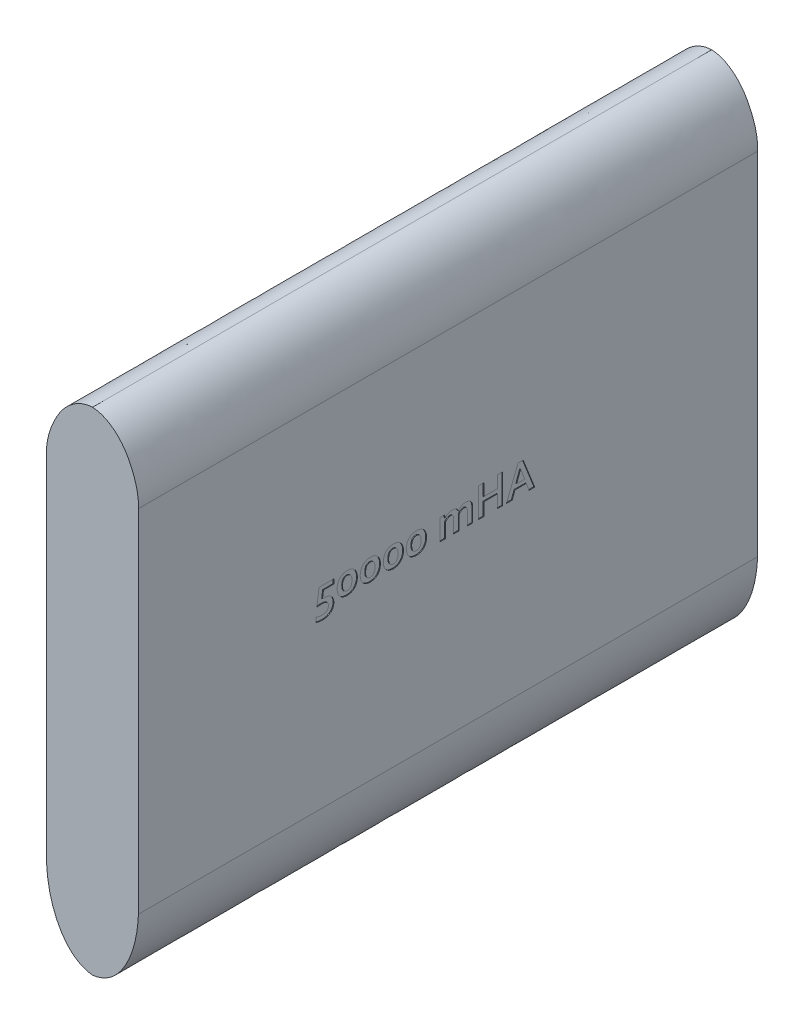
from build123d import *

# Parameters (mm, degrees)
BOSS_EXTRU_1_DEPTH      = 200
ENL_V_MAT_EXTRU_1_DEPTH = 0.25


with BuildPart() as part:
    # Esquisse1 → Boss.-Extru.1 (new body)
    with BuildSketch(Plane.XY):
        with BuildLine():
            Line((174.006058194, 716.318776113), (174.006058194, 829.741721472))
            add(Edge.make_bspline(
                [(174.006058194, 829.741721472), (173.82511917, 833.547287243), (175.407603849, 839.077084094), (180.025968772, 847.096630759), (185.137818189, 850.602101048), (188.860692851, 850.687245442)],
                knots=[0, 0, 0, 0, 0.407149215, 0.601731979, 1, 1, 1, 1], degree=3))
            add(Edge.make_bspline(
                [(203.715327508, 829.741721472), (203.896266532, 833.547287243), (202.313781853, 839.077084094), (197.69541693, 847.096630759), (192.583567513, 850.602101048), (188.860692851, 850.687245442)],
                knots=[0, 0, 0, 0, 0.407149215, 0.601731979, 1, 1, 1, 1], degree=3))
            Line((203.715327508, 829.741721472), (203.715327508, 716.318776113))
            add(Edge.make_bspline(
                [(203.715327508, 716.318776113), (203.491349962, 711.367000978), (201.646435697, 701.175584334), (194.585398748, 692.499736476), (188.860692851, 691.841289865)],
                knots=[0, 0, 0, 0, 0.482435896, 1, 1, 1, 1], degree=3))
            add(Edge.make_bspline(
                [(174.006058194, 716.318776113), (174.23003574, 711.367000978), (176.074950005, 701.175584334), (183.135986954, 692.499736476), (188.860692851, 691.841289865)],
                knots=[0, 0, 0, 0, 0.482435896, 1, 1, 1, 1], degree=3))
        make_face()
    extrude(amount=BOSS_EXTRU_1_DEPTH)

    # Esquisse3 → Enlèv. mat.-Extru.1 (cut)
    with BuildSketch(Plane(origin=(203.715327508, 0, 0), x_dir=(0, 0, -1), z_dir=(1, 0, 0))):
        with BuildLine():
            add(Edge.make_bspline(
                [(-140.546667276, 774.83369835), (-140.485009973, 774.835240725), (-140.370017677, 774.838117291), (-140.254996381, 774.839358124), (-140.201647938, 774.839933639)],
                knots=[0, 0, 0, 0, 0.000185027, 0.00034508, 0.00034508, 0.00034508, 0.00034508], degree=3))
            add(Edge.make_bspline(
                [(-140.201647938, 774.839933639), (-140.068519111, 774.837888483), (-139.809949865, 774.833916283), (-139.434787858, 774.793284398), (-139.084338789, 774.729802163), (-138.758370391, 774.641085619), (-138.458484512, 774.525851327), (-138.182172614, 774.391894468), (-137.933568705, 774.233068697), (-137.711166346, 774.053106908), (-137.515136552, 773.85242679), (-137.343305442, 773.633502134), (-137.198672667, 773.393874723), (-137.08143951, 773.135959952), (-136.986524121, 772.862083331), (-136.921275975, 772.572784649), (-136.880260316, 772.268713409), (-136.876172688, 772.06120912), (-136.874081915, 771.955073152)],
                knots=[0, 0, 0, 0, 0.000399253, 0.000775449, 0.00113052, 0.001466847, 0.001787229, 0.002093041, 0.002386512, 0.002670215, 0.002949468, 0.003226368, 0.00350333, 0.00378698, 0.004074871, 0.00437133, 0.004675278, 0.004993523, 0.004993523, 0.004993523, 0.004993523], degree=3))
            add(Edge.make_bspline(
                [(-136.874081915, 771.955073152), (-136.876682163, 771.847529419), (-136.881823113, 771.634904785), (-136.928618865, 771.321982443), (-137.006694486, 771.020222629), (-137.111666766, 770.729963965), (-137.246610554, 770.453562607), (-137.414630104, 770.197593248), (-137.608849049, 769.958522184), (-137.832376256, 769.740204818), (-138.082671873, 769.541611763), (-138.361614594, 769.367253451), (-138.665568947, 769.212339301), (-138.997477675, 769.084889337), (-139.354052186, 768.97880796), (-139.737455385, 768.909438772), (-140.144294484, 768.860953434), (-140.423885061, 768.856396106), (-140.567451573, 768.854055971)],
                knots=[0, 0, 0, 0, 0.000322485, 0.000637585, 0.000946601, 0.001256287, 0.001562098, 0.001867061, 0.002172845, 0.002484429, 0.002802538, 0.003129486, 0.003469689, 0.003824395, 0.004194688, 0.004583976, 0.004991841, 0.005422322, 0.005422322, 0.005422322, 0.005422322], degree=3))
            add(Edge.make_bspline(
                [(-140.567451573, 768.854055971), (-140.663127679, 768.854747635), (-140.851997146, 768.856113015), (-141.131157054, 768.882203987), (-141.403773032, 768.912336319), (-141.748701829, 768.980358185), (-142.156168903, 769.08310677), (-142.465253448, 769.199104577), (-142.614704873, 769.255192912)],
                knots=[0, 0, 0, 0, 0.000286891, 0.000566337, 0.000840635, 0.001109268, 0.001620443, 0.002099015, 0.002099015, 0.002099015, 0.002099015], degree=3))
            Line((-142.614704873, 769.255192912), (-142.614704873, 770.716329023))
            add(Edge.make_bspline(
                [(-142.614704873, 770.716329023), (-142.527712474, 770.682912728), (-142.357052527, 770.617357309), (-142.100582337, 770.535335396), (-141.852378036, 770.463091619), (-141.532803544, 770.392923016), (-141.145520089, 770.33091666), (-140.836518896, 770.321741955), (-140.685922069, 770.317270512)],
                knots=[0, 0, 0, 0, 0.000279508, 0.000548334, 0.000807563, 0.001054643, 0.001529654, 0.001981252, 0.001981252, 0.001981252, 0.001981252], degree=3))
            add(Edge.make_bspline(
                [(-140.685922069, 770.317270512), (-140.595804046, 770.318895283), (-140.422190904, 770.322025418), (-140.172876184, 770.344929056), (-139.943951759, 770.38146103), (-139.735760996, 770.434915752), (-139.547463568, 770.504854049), (-139.376565358, 770.582973282), (-139.222669303, 770.672666834), (-139.087392828, 770.775255926), (-138.966823786, 770.887207037), (-138.867717919, 771.013314555), (-138.782881252, 771.147282878), (-138.716741718, 771.29240751), (-138.664722574, 771.444877475), (-138.630390509, 771.605447654), (-138.605722736, 771.770712341), (-138.604135453, 771.883619196), (-138.603335463, 771.940524144)],
                knots=[0, 0, 0, 0, 0.000270324, 0.000520781, 0.000750398, 0.000965151, 0.001164388, 0.00135223, 0.001528321, 0.001697506, 0.001860699, 0.0020204, 0.002177263, 0.002335347, 0.002497691, 0.002659555, 0.002827394, 0.002997939, 0.002997939, 0.002997939, 0.002997939], degree=3))
            add(Edge.make_bspline(
                [(-138.603335463, 771.940524144), (-138.605059399, 772.001554177), (-138.608421844, 772.120590055), (-138.630806238, 772.293525283), (-138.670830289, 772.455862709), (-138.726730594, 772.608162167), (-138.79964626, 772.750074953), (-138.89009429, 772.882378912), (-139.003233382, 772.999614535), (-139.133897504, 773.106596868), (-139.281592455, 773.203037668), (-139.450800106, 773.283331789), (-139.636727503, 773.354254621), (-139.843237511, 773.409288128), (-140.067980277, 773.455237961), (-140.313738658, 773.488251082), (-140.580336447, 773.506341521), (-140.764874896, 773.508579033), (-140.860510168, 773.509738602)],
                knots=[0, 0, 0, 0, 0.000183091, 0.000357109, 0.000521948, 0.000683719, 0.000842674, 0.000999496, 0.001162689, 0.001329547, 0.00150538, 0.001690361, 0.001890322, 0.002101598, 0.002330678, 0.002578177, 0.002844873, 0.003131764, 0.003131764, 0.003131764, 0.003131764], degree=3))
            add(Edge.make_bspline(
                [(-140.860510168, 773.509738602), (-140.974159366, 773.50781456), (-141.209975207, 773.503822278), (-141.575510221, 773.480635937), (-141.967229148, 773.43845212), (-142.235878492, 773.397849158), (-142.375685452, 773.376719098)],
                knots=[0, 0, 0, 0, 0.000340964, 0.000707481, 0.001098364, 0.001522512, 0.001522512, 0.001522512, 0.001522512], degree=3))
            Line((-142.375685452, 773.376719098), (-141.65447033, 778.564479744))
            Line((-141.65447033, 778.564479744), (-136.880317204, 778.564479744))
            Line((-136.880317204, 778.564479744), (-136.880317204, 777.101265203))
            Line((-136.880317204, 777.101265203), (-140.236981244, 777.101265203))
            Line((-140.236981244, 777.101265203), (-140.546667276, 774.83369835))
        make_face()
        with BuildLine():
            add(Edge.make_bspline(
                [(-129.291970202, 775.23899215), (-129.294057874, 775.117627647), (-129.298161303, 774.87907933), (-129.339706601, 774.528315653), (-129.402600755, 774.190779425), (-129.494571438, 773.868253875), (-129.610365992, 773.562533487), (-129.750882617, 773.275654926), (-129.922073287, 773.013158699), (-130.111850547, 772.768317), (-130.329829554, 772.548865344), (-130.57337718, 772.354005454), (-130.842487622, 772.183449377), (-131.136129188, 772.037989561), (-131.453684852, 771.919446324), (-131.797576961, 771.840854899), (-132.164177063, 771.789166311), (-132.417048325, 771.783428831), (-132.546791184, 771.780485053)],
                knots=[0, 0, 0, 0, 0.000363939, 0.000715341, 0.001058156, 0.001393041, 0.00171999, 0.002037881, 0.002349208, 0.002658559, 0.002965724, 0.00327474, 0.003592441, 0.003919627, 0.004256307, 0.004606675, 0.004975864, 0.005364886, 0.005364886, 0.005364886, 0.005364886], degree=3))
            add(Edge.make_bspline(
                [(-132.546791184, 771.780485053), (-132.674451607, 771.783468212), (-132.923862323, 771.789296421), (-133.285699177, 771.840701509), (-133.626530131, 771.92022043), (-133.942423387, 772.037499275), (-134.234610031, 772.183376137), (-134.502085455, 772.355135129), (-134.747280825, 772.549276786), (-134.969049244, 772.76822434), (-135.163393066, 773.012394669), (-135.336069767, 773.27613215), (-135.481126548, 773.562291327), (-135.601496238, 773.867753538), (-135.695040467, 774.190731523), (-135.76002194, 774.528229534), (-135.804293075, 774.87894579), (-135.808026893, 775.117609567), (-135.809925885, 775.23899215)],
                knots=[0, 0, 0, 0, 0.000382792, 0.000747863, 0.001094188, 0.001430868, 0.001756194, 0.002072143, 0.002382783, 0.002692887, 0.003004825, 0.003317281, 0.003637042, 0.003965493, 0.004300952, 0.004644164, 0.004995805, 0.005359744, 0.005359744, 0.005359744, 0.005359744], degree=3))
            add(Edge.make_bspline(
                [(-135.809925885, 775.23899215), (-135.808027098, 775.360374868), (-135.804293683, 775.59903891), (-135.760019629, 775.949753247), (-135.695048831, 776.287258279), (-135.60146604, 776.610210901), (-135.481235494, 776.915764628), (-135.335414386, 777.20211382), (-135.164159308, 777.467489641), (-134.968383905, 777.711927912), (-134.747292703, 777.932657317), (-134.50328993, 778.129417387), (-134.234338252, 778.29849302), (-133.94244216, 778.442993963), (-133.625753399, 778.556442254), (-133.28628588, 778.640922241), (-132.92360555, 778.687709729), (-132.674396069, 778.694184113), (-132.546791184, 778.697499248)],
                knots=[0, 0, 0, 0, 0.000363939, 0.000715581, 0.001058792, 0.001394251, 0.001722702, 0.002042463, 0.002356664, 0.002668601, 0.002980172, 0.003292109, 0.003606942, 0.003931343, 0.00426731, 0.004614128, 0.004978921, 0.005361713, 0.005361713, 0.005361713, 0.005361713], degree=3))
            add(Edge.make_bspline(
                [(-132.546791184, 778.697499248), (-132.417103831, 778.694220555), (-132.164432452, 778.687832641), (-131.796994758, 778.64077474), (-131.45445858, 778.557217752), (-131.13610581, 778.442506788), (-130.842760514, 778.298416859), (-130.572172743, 778.130547238), (-130.329810986, 777.933068853), (-130.112514335, 777.71184886), (-129.921313392, 777.466714367), (-129.751530902, 777.202600777), (-129.610257278, 776.915521358), (-129.494601684, 776.609710799), (-129.402592363, 776.287210321), (-129.339708921, 775.949667142), (-129.298160693, 775.598905367), (-129.294057668, 775.360356788), (-129.291970202, 775.23899215)],
                knots=[0, 0, 0, 0, 0.000389022, 0.000757936, 0.001108791, 0.001444758, 0.001771025, 0.002087615, 0.002397935, 0.002706581, 0.003015932, 0.00332901, 0.003646901, 0.003973849, 0.004308734, 0.004651549, 0.005002951, 0.00536689, 0.00536689, 0.00536689, 0.00536689], degree=3))
        make_face()
        with BuildLine():
            add(Edge.make_bspline(
                [(-131.02122375, 775.23899215), (-131.022382637, 775.322160343), (-131.024635923, 775.48386872), (-131.043081685, 775.718553707), (-131.075194854, 775.938279319), (-131.114569144, 776.143962274), (-131.1713829, 776.334273995), (-131.240327868, 776.509076182), (-131.318479454, 776.671215171), (-131.4123635, 776.81622254), (-131.51656081, 776.946050797), (-131.630754569, 777.059645231), (-131.757829273, 777.153377694), (-131.893184249, 777.234158364), (-132.041902625, 777.294383265), (-132.201557251, 777.334526878), (-132.370463967, 777.363603349), (-132.487077614, 777.366050906), (-132.546791184, 777.36730421)],
                knots=[0, 0, 0, 0, 0.000249489, 0.000485096, 0.000705547, 0.000915468, 0.001112755, 0.001300332, 0.001478799, 0.001651759, 0.001817304, 0.001977505, 0.002133387, 0.002289878, 0.002449282, 0.00261262, 0.002783128, 0.002962066, 0.002962066, 0.002962066, 0.002962066], degree=3))
            add(Edge.make_bspline(
                [(-132.546791184, 777.36730421), (-132.607191427, 777.366031148), (-132.725170792, 777.363544485), (-132.895547639, 777.334838974), (-133.056401014, 777.294011847), (-133.206498929, 777.234112132), (-133.34382354, 777.154074516), (-133.471176198, 777.058927827), (-133.587298958, 776.946728223), (-133.691986112, 776.816825535), (-133.782473559, 776.669940713), (-133.864839438, 776.510243438), (-133.92966256, 776.33364661), (-133.987597296, 776.144075843), (-134.026622953, 775.938246436), (-134.058837302, 775.718563327), (-134.077253876, 775.483866078), (-134.079511314, 775.322159446), (-134.080672336, 775.23899215)],
                knots=[0, 0, 0, 0, 0.000181014, 0.000353574, 0.000516913, 0.000678242, 0.000836531, 0.000992413, 0.001154104, 0.001319649, 0.001491494, 0.00167089, 0.001857718, 0.002055004, 0.002264926, 0.002485377, 0.002720983, 0.002970472, 0.002970472, 0.002970472, 0.002970472], degree=3))
            add(Edge.make_bspline(
                [(-134.080672336, 775.23899215), (-134.079511314, 775.155824855), (-134.077253876, 774.994118223), (-134.058837302, 774.759420973), (-134.026622953, 774.539737865), (-133.987597296, 774.333908458), (-133.92966256, 774.144337691), (-133.864839438, 773.967740863), (-133.782473559, 773.808043588), (-133.691986112, 773.661158766), (-133.587298958, 773.531256078), (-133.471176198, 773.419056474), (-133.34382354, 773.323909785), (-133.206498929, 773.243872169), (-133.056401014, 773.183972454), (-132.895547639, 773.143145327), (-132.725170792, 773.114439816), (-132.607191427, 773.111953153), (-132.546791184, 773.110680091)],
                knots=[0, 0, 0, 0, 0.000249489, 0.000485096, 0.000705547, 0.000915468, 0.001112755, 0.001299582, 0.001478979, 0.001650823, 0.001816369, 0.001978059, 0.002133942, 0.00229223, 0.00245356, 0.002616898, 0.002789458, 0.002970472, 0.002970472, 0.002970472, 0.002970472], degree=3))
            add(Edge.make_bspline(
                [(-132.546791184, 773.110680091), (-132.487077614, 773.111933395), (-132.370463967, 773.114380952), (-132.201557251, 773.143457423), (-132.041902625, 773.183601036), (-131.893184249, 773.243825937), (-131.757829273, 773.324606606), (-131.630754569, 773.41833907), (-131.51656081, 773.531933504), (-131.4123635, 773.661761761), (-131.318479454, 773.806769129), (-131.240327868, 773.968908119), (-131.1713829, 774.143710306), (-131.114569144, 774.334022027), (-131.075194854, 774.539704982), (-131.043081685, 774.759430593), (-131.024635923, 774.994115581), (-131.022382637, 775.155823957), (-131.02122375, 775.23899215)],
                knots=[0, 0, 0, 0, 0.000178938, 0.000349445, 0.000512784, 0.000672188, 0.000828678, 0.000984561, 0.001144762, 0.001310307, 0.001483267, 0.001661734, 0.001849311, 0.002046598, 0.002256519, 0.00247697, 0.002712576, 0.002962066, 0.002962066, 0.002962066, 0.002962066], degree=3))
        make_face(mode=Mode.SUBTRACT)
        with BuildLine():
            add(Edge.make_bspline(
                [(-121.842877992, 775.23899215), (-121.844965664, 775.117627647), (-121.849069094, 774.87907933), (-121.890614391, 774.528315653), (-121.953508545, 774.190779425), (-122.045479228, 773.868253875), (-122.161273783, 773.562533487), (-122.301790407, 773.275654926), (-122.472981077, 773.013158699), (-122.662758338, 772.768317), (-122.880737345, 772.548865344), (-123.124284971, 772.354005454), (-123.393395412, 772.183449377), (-123.687036979, 772.037989561), (-124.004592642, 771.919446324), (-124.348484751, 771.840854899), (-124.715084854, 771.789166311), (-124.967956115, 771.783428831), (-125.097698974, 771.780485053)],
                knots=[0, 0, 0, 0, 0.000363939, 0.000715341, 0.001058156, 0.001393041, 0.00171999, 0.002037881, 0.002349208, 0.002658559, 0.002965724, 0.00327474, 0.003592441, 0.003919627, 0.004256307, 0.004606675, 0.004975864, 0.005364886, 0.005364886, 0.005364886, 0.005364886], degree=3))
            add(Edge.make_bspline(
                [(-125.097698974, 771.780485053), (-125.225359397, 771.783468212), (-125.474770114, 771.789296421), (-125.836606968, 771.840701509), (-126.177437921, 771.92022043), (-126.493331177, 772.037499275), (-126.785517821, 772.183376137), (-127.052993245, 772.355135129), (-127.298188615, 772.549276786), (-127.519957035, 772.76822434), (-127.714300857, 773.012394669), (-127.886977557, 773.27613215), (-128.032034338, 773.562291327), (-128.152404028, 773.867753538), (-128.245948258, 774.190731523), (-128.31092973, 774.528229534), (-128.355200866, 774.87894579), (-128.358934684, 775.117609567), (-128.360833675, 775.23899215)],
                knots=[0, 0, 0, 0, 0.000382792, 0.000747863, 0.001094188, 0.001430868, 0.001756194, 0.002072143, 0.002382783, 0.002692887, 0.003004825, 0.003317281, 0.003637042, 0.003965493, 0.004300952, 0.004644164, 0.004995805, 0.005359744, 0.005359744, 0.005359744, 0.005359744], degree=3))
            add(Edge.make_bspline(
                [(-128.360833675, 775.23899215), (-128.358934889, 775.360374868), (-128.355201473, 775.59903891), (-128.310927419, 775.949753247), (-128.245956621, 776.287258279), (-128.15237383, 776.610210901), (-128.032143284, 776.915764628), (-127.886322176, 777.20211382), (-127.715067099, 777.467489641), (-127.519291696, 777.711927912), (-127.298200494, 777.932657317), (-127.05419772, 778.129417387), (-126.785246042, 778.29849302), (-126.49334995, 778.442993963), (-126.176661189, 778.556442254), (-125.83719367, 778.640922241), (-125.47451334, 778.687709729), (-125.22530386, 778.694184113), (-125.097698974, 778.697499248)],
                knots=[0, 0, 0, 0, 0.000363939, 0.000715581, 0.001058792, 0.001394251, 0.001722702, 0.002042463, 0.002356664, 0.002668601, 0.002980172, 0.003292109, 0.003606942, 0.003931343, 0.00426731, 0.004614128, 0.004978921, 0.005361713, 0.005361713, 0.005361713, 0.005361713], degree=3))
            add(Edge.make_bspline(
                [(-125.097698974, 778.697499248), (-124.968011621, 778.694220555), (-124.715340243, 778.687832641), (-124.347902548, 778.64077474), (-124.00536637, 778.557217752), (-123.6870136, 778.442506788), (-123.393668305, 778.298416859), (-123.123080534, 778.130547238), (-122.880718777, 777.933068853), (-122.663422125, 777.71184886), (-122.472221182, 777.466714367), (-122.302438693, 777.202600777), (-122.161165068, 776.915521358), (-122.045509474, 776.609710799), (-121.953500153, 776.287210321), (-121.890616712, 775.949667142), (-121.849068483, 775.598905367), (-121.844965458, 775.360356788), (-121.842877992, 775.23899215)],
                knots=[0, 0, 0, 0, 0.000389022, 0.000757936, 0.001108791, 0.001444758, 0.001771025, 0.002087615, 0.002397935, 0.002706581, 0.003015932, 0.00332901, 0.003646901, 0.003973849, 0.004308734, 0.004651549, 0.005002951, 0.00536689, 0.00536689, 0.00536689, 0.00536689], degree=3))
        make_face()
        with BuildLine():
            add(Edge.make_bspline(
                [(-123.572131541, 775.23899215), (-123.573290427, 775.322160343), (-123.575543713, 775.48386872), (-123.593989476, 775.718553707), (-123.626102645, 775.938279319), (-123.665476935, 776.143962274), (-123.72229069, 776.334273995), (-123.791235658, 776.509076182), (-123.869387245, 776.671215171), (-123.96327129, 776.81622254), (-124.067468601, 776.946050797), (-124.18166236, 777.059645231), (-124.308737064, 777.153377694), (-124.44409204, 777.234158364), (-124.592810416, 777.294383265), (-124.752465042, 777.334526878), (-124.921371758, 777.363603349), (-125.037985405, 777.366050906), (-125.097698974, 777.36730421)],
                knots=[0, 0, 0, 0, 0.000249489, 0.000485096, 0.000705547, 0.000915468, 0.001112755, 0.001300332, 0.001478799, 0.001651759, 0.001817304, 0.001977505, 0.002133387, 0.002289878, 0.002449282, 0.00261262, 0.002783128, 0.002962066, 0.002962066, 0.002962066, 0.002962066], degree=3))
            add(Edge.make_bspline(
                [(-125.097698974, 777.36730421), (-125.158099218, 777.366031148), (-125.276078583, 777.363544485), (-125.44645543, 777.334838974), (-125.607308804, 777.294011847), (-125.75740672, 777.234112132), (-125.894731331, 777.154074516), (-126.022083988, 777.058927827), (-126.138206748, 776.946728223), (-126.242893903, 776.816825535), (-126.333381349, 776.669940713), (-126.415747228, 776.510243438), (-126.480570351, 776.33364661), (-126.538505087, 776.144075843), (-126.577530744, 775.938246436), (-126.609745092, 775.718563327), (-126.628161666, 775.483866078), (-126.630419104, 775.322159446), (-126.631580127, 775.23899215)],
                knots=[0, 0, 0, 0, 0.000181014, 0.000353574, 0.000516913, 0.000678242, 0.000836531, 0.000992413, 0.001154104, 0.001319649, 0.001491494, 0.00167089, 0.001857718, 0.002055004, 0.002264926, 0.002485377, 0.002720983, 0.002970472, 0.002970472, 0.002970472, 0.002970472], degree=3))
            add(Edge.make_bspline(
                [(-126.631580127, 775.23899215), (-126.630419104, 775.155824855), (-126.628161666, 774.994118223), (-126.609745092, 774.759420973), (-126.577530744, 774.539737865), (-126.538505087, 774.333908458), (-126.480570351, 774.144337691), (-126.415747228, 773.967740863), (-126.333381349, 773.808043588), (-126.242893903, 773.661158766), (-126.138206748, 773.531256078), (-126.022083988, 773.419056474), (-125.894731331, 773.323909785), (-125.75740672, 773.243872169), (-125.607308804, 773.183972454), (-125.44645543, 773.143145327), (-125.276078583, 773.114439816), (-125.158099218, 773.111953153), (-125.097698974, 773.110680091)],
                knots=[0, 0, 0, 0, 0.000249489, 0.000485096, 0.000705547, 0.000915468, 0.001112755, 0.001299582, 0.001478979, 0.001650823, 0.001816369, 0.001978059, 0.002133942, 0.00229223, 0.00245356, 0.002616898, 0.002789458, 0.002970472, 0.002970472, 0.002970472, 0.002970472], degree=3))
            add(Edge.make_bspline(
                [(-125.097698974, 773.110680091), (-125.037985405, 773.111933395), (-124.921371758, 773.114380952), (-124.752465042, 773.143457423), (-124.592810416, 773.183601036), (-124.44409204, 773.243825937), (-124.308737064, 773.324606606), (-124.18166236, 773.41833907), (-124.067468601, 773.531933504), (-123.96327129, 773.661761761), (-123.869387245, 773.806769129), (-123.791235658, 773.968908119), (-123.72229069, 774.143710306), (-123.665476935, 774.334022027), (-123.626102645, 774.539704982), (-123.593989476, 774.759430593), (-123.575543713, 774.994115581), (-123.573290427, 775.155823957), (-123.572131541, 775.23899215)],
                knots=[0, 0, 0, 0, 0.000178938, 0.000349445, 0.000512784, 0.000672188, 0.000828678, 0.000984561, 0.001144762, 0.001310307, 0.001483267, 0.001661734, 0.001849311, 0.002046598, 0.002256519, 0.00247697, 0.002712576, 0.002962066, 0.002962066, 0.002962066, 0.002962066], degree=3))
        make_face(mode=Mode.SUBTRACT)
        with BuildLine():
            add(Edge.make_bspline(
                [(-114.393785782, 775.23899215), (-114.395873455, 775.117627647), (-114.399976884, 774.87907933), (-114.441522182, 774.528315653), (-114.504416336, 774.190779425), (-114.596387019, 773.868253875), (-114.712181573, 773.562533487), (-114.852698198, 773.275654926), (-115.023888868, 773.013158699), (-115.213666128, 772.768317), (-115.431645135, 772.548865344), (-115.675192761, 772.354005454), (-115.944303203, 772.183449377), (-116.237944769, 772.037989561), (-116.555500433, 771.919446324), (-116.899392542, 771.840854899), (-117.265992644, 771.789166311), (-117.518863906, 771.783428831), (-117.648606765, 771.780485053)],
                knots=[0, 0, 0, 0, 0.000363939, 0.000715341, 0.001058156, 0.001393041, 0.00171999, 0.002037881, 0.002349208, 0.002658559, 0.002965724, 0.00327474, 0.003592441, 0.003919627, 0.004256307, 0.004606675, 0.004975864, 0.005364886, 0.005364886, 0.005364886, 0.005364886], degree=3))
            add(Edge.make_bspline(
                [(-117.648606765, 771.780485053), (-117.776267188, 771.783468212), (-118.025677904, 771.789296421), (-118.387514758, 771.840701509), (-118.728345712, 771.92022043), (-119.044238968, 772.037499275), (-119.336425612, 772.183376137), (-119.603901036, 772.355135129), (-119.849096406, 772.549276786), (-120.070864825, 772.76822434), (-120.265208647, 773.012394669), (-120.437885348, 773.27613215), (-120.582942129, 773.562291327), (-120.703311819, 773.867753538), (-120.796856048, 774.190731523), (-120.861837521, 774.528229534), (-120.906108656, 774.87894579), (-120.909842474, 775.117609567), (-120.911741466, 775.23899215)],
                knots=[0, 0, 0, 0, 0.000382792, 0.000747863, 0.001094188, 0.001430868, 0.001756194, 0.002072143, 0.002382783, 0.002692887, 0.003004825, 0.003317281, 0.003637042, 0.003965493, 0.004300952, 0.004644164, 0.004995805, 0.005359744, 0.005359744, 0.005359744, 0.005359744], degree=3))
            add(Edge.make_bspline(
                [(-120.911741466, 775.23899215), (-120.909842679, 775.360374868), (-120.906109264, 775.59903891), (-120.86183521, 775.949753247), (-120.796864412, 776.287258279), (-120.703281621, 776.610210901), (-120.583051075, 776.915764628), (-120.437229967, 777.20211382), (-120.265974889, 777.467489641), (-120.070199486, 777.711927912), (-119.849108284, 777.932657317), (-119.605105511, 778.129417387), (-119.336153833, 778.29849302), (-119.044257741, 778.442993963), (-118.72756898, 778.556442254), (-118.388101461, 778.640922241), (-118.025421131, 778.687709729), (-117.77621165, 778.694184113), (-117.648606765, 778.697499248)],
                knots=[0, 0, 0, 0, 0.000363939, 0.000715581, 0.001058792, 0.001394251, 0.001722702, 0.002042463, 0.002356664, 0.002668601, 0.002980172, 0.003292109, 0.003606942, 0.003931343, 0.00426731, 0.004614128, 0.004978921, 0.005361713, 0.005361713, 0.005361713, 0.005361713], degree=3))
            add(Edge.make_bspline(
                [(-117.648606765, 778.697499248), (-117.518919412, 778.694220555), (-117.266248033, 778.687832641), (-116.898810339, 778.64077474), (-116.556274161, 778.557217752), (-116.237921391, 778.442506788), (-115.944576095, 778.298416859), (-115.673988324, 778.130547238), (-115.431626567, 777.933068853), (-115.214329916, 777.71184886), (-115.023128973, 777.466714367), (-114.853346483, 777.202600777), (-114.712072859, 776.915521358), (-114.596417265, 776.609710799), (-114.504407944, 776.287210321), (-114.441524502, 775.949667142), (-114.399976274, 775.598905367), (-114.395873249, 775.360356788), (-114.393785782, 775.23899215)],
                knots=[0, 0, 0, 0, 0.000389022, 0.000757936, 0.001108791, 0.001444758, 0.001771025, 0.002087615, 0.002397935, 0.002706581, 0.003015932, 0.00332901, 0.003646901, 0.003973849, 0.004308734, 0.004651549, 0.005002951, 0.00536689, 0.00536689, 0.00536689, 0.00536689], degree=3))
        make_face()
        with BuildLine():
            add(Edge.make_bspline(
                [(-116.123039331, 775.23899215), (-116.124198218, 775.322160343), (-116.126451504, 775.48386872), (-116.144897266, 775.718553707), (-116.177010435, 775.938279319), (-116.216384725, 776.143962274), (-116.273198481, 776.334273995), (-116.342143449, 776.509076182), (-116.420295035, 776.671215171), (-116.514179081, 776.81622254), (-116.618376391, 776.946050797), (-116.73257015, 777.059645231), (-116.859644854, 777.153377694), (-116.99499983, 777.234158364), (-117.143718206, 777.294383265), (-117.303372832, 777.334526878), (-117.472279548, 777.363603349), (-117.588893195, 777.366050906), (-117.648606765, 777.36730421)],
                knots=[0, 0, 0, 0, 0.000249489, 0.000485096, 0.000705547, 0.000915468, 0.001112755, 0.001300332, 0.001478799, 0.001651759, 0.001817304, 0.001977505, 0.002133387, 0.002289878, 0.002449282, 0.00261262, 0.002783128, 0.002962066, 0.002962066, 0.002962066, 0.002962066], degree=3))
            add(Edge.make_bspline(
                [(-117.648606765, 777.36730421), (-117.709007008, 777.366031148), (-117.826986373, 777.363544485), (-117.99736322, 777.334838974), (-118.158216595, 777.294011847), (-118.30831451, 777.234112132), (-118.445639121, 777.154074516), (-118.572991779, 777.058927827), (-118.689114539, 776.946728223), (-118.793801693, 776.816825535), (-118.88428914, 776.669940713), (-118.966655019, 776.510243438), (-119.031478141, 776.33364661), (-119.089412877, 776.144075843), (-119.128438534, 775.938246436), (-119.160652883, 775.718563327), (-119.179069457, 775.483866078), (-119.181326895, 775.322159446), (-119.182487917, 775.23899215)],
                knots=[0, 0, 0, 0, 0.000181014, 0.000353574, 0.000516913, 0.000678242, 0.000836531, 0.000992413, 0.001154104, 0.001319649, 0.001491494, 0.00167089, 0.001857718, 0.002055004, 0.002264926, 0.002485377, 0.002720983, 0.002970472, 0.002970472, 0.002970472, 0.002970472], degree=3))
            add(Edge.make_bspline(
                [(-119.182487917, 775.23899215), (-119.181326895, 775.155824855), (-119.179069457, 774.994118223), (-119.160652883, 774.759420973), (-119.128438534, 774.539737865), (-119.089412877, 774.333908458), (-119.031478141, 774.144337691), (-118.966655019, 773.967740863), (-118.88428914, 773.808043588), (-118.793801693, 773.661158766), (-118.689114539, 773.531256078), (-118.572991779, 773.419056474), (-118.445639121, 773.323909785), (-118.30831451, 773.243872169), (-118.158216595, 773.183972454), (-117.99736322, 773.143145327), (-117.826986373, 773.114439816), (-117.709007008, 773.111953153), (-117.648606765, 773.110680091)],
                knots=[0, 0, 0, 0, 0.000249489, 0.000485096, 0.000705547, 0.000915468, 0.001112755, 0.001299582, 0.001478979, 0.001650823, 0.001816369, 0.001978059, 0.002133942, 0.00229223, 0.00245356, 0.002616898, 0.002789458, 0.002970472, 0.002970472, 0.002970472, 0.002970472], degree=3))
            add(Edge.make_bspline(
                [(-117.648606765, 773.110680091), (-117.588893195, 773.111933395), (-117.472279548, 773.114380952), (-117.303372832, 773.143457423), (-117.143718206, 773.183601036), (-116.99499983, 773.243825937), (-116.859644854, 773.324606606), (-116.73257015, 773.41833907), (-116.618376391, 773.531933504), (-116.514179081, 773.661761761), (-116.420295035, 773.806769129), (-116.342143449, 773.968908119), (-116.273198481, 774.143710306), (-116.216384725, 774.334022027), (-116.177010435, 774.539704982), (-116.144897266, 774.759430593), (-116.126451504, 774.994115581), (-116.124198218, 775.155823957), (-116.123039331, 775.23899215)],
                knots=[0, 0, 0, 0, 0.000178938, 0.000349445, 0.000512784, 0.000672188, 0.000828678, 0.000984561, 0.001144762, 0.001310307, 0.001483267, 0.001661734, 0.001849311, 0.002046598, 0.002256519, 0.00247697, 0.002712576, 0.002962066, 0.002962066, 0.002962066, 0.002962066], degree=3))
        make_face(mode=Mode.SUBTRACT)
        with BuildLine():
            add(Edge.make_bspline(
                [(-106.944693573, 775.23899215), (-106.946781245, 775.117627647), (-106.950884675, 774.87907933), (-106.992429972, 774.528315653), (-107.055324126, 774.190779425), (-107.147294809, 773.868253875), (-107.263089364, 773.562533487), (-107.403605988, 773.275654926), (-107.574796658, 773.013158699), (-107.764573919, 772.768317), (-107.982552926, 772.548865344), (-108.226100552, 772.354005454), (-108.495210993, 772.183449377), (-108.78885256, 772.037989561), (-109.106408223, 771.919446324), (-109.450300332, 771.840854899), (-109.816900435, 771.789166311), (-110.069771696, 771.783428831), (-110.199514555, 771.780485053)],
                knots=[0, 0, 0, 0, 0.000363939, 0.000715341, 0.001058156, 0.001393041, 0.00171999, 0.002037881, 0.002349208, 0.002658559, 0.002965724, 0.00327474, 0.003592441, 0.003919627, 0.004256307, 0.004606675, 0.004975864, 0.005364886, 0.005364886, 0.005364886, 0.005364886], degree=3))
            add(Edge.make_bspline(
                [(-110.199514555, 771.780485053), (-110.327174978, 771.783468212), (-110.576585695, 771.789296421), (-110.938422549, 771.840701509), (-111.279253502, 771.92022043), (-111.595146758, 772.037499275), (-111.887333402, 772.183376137), (-112.154808826, 772.355135129), (-112.400004196, 772.549276786), (-112.621772616, 772.76822434), (-112.816116438, 773.012394669), (-112.988793138, 773.27613215), (-113.133849919, 773.562291327), (-113.254219609, 773.867753538), (-113.347763839, 774.190731523), (-113.412745311, 774.528229534), (-113.457016447, 774.87894579), (-113.460750265, 775.117609567), (-113.462649256, 775.23899215)],
                knots=[0, 0, 0, 0, 0.000382792, 0.000747863, 0.001094188, 0.001430868, 0.001756194, 0.002072143, 0.002382783, 0.002692887, 0.003004825, 0.003317281, 0.003637042, 0.003965493, 0.004300952, 0.004644164, 0.004995805, 0.005359744, 0.005359744, 0.005359744, 0.005359744], degree=3))
            add(Edge.make_bspline(
                [(-113.462649256, 775.23899215), (-113.46075047, 775.360374868), (-113.457017054, 775.59903891), (-113.412743, 775.949753247), (-113.347772202, 776.287258279), (-113.254189411, 776.610210901), (-113.133958865, 776.915764628), (-112.988137757, 777.20211382), (-112.81688268, 777.467489641), (-112.621107277, 777.711927912), (-112.400016075, 777.932657317), (-112.156013301, 778.129417387), (-111.887061623, 778.29849302), (-111.595165531, 778.442993963), (-111.27847677, 778.556442254), (-110.939009251, 778.640922241), (-110.576328921, 778.687709729), (-110.32711944, 778.694184113), (-110.199514555, 778.697499248)],
                knots=[0, 0, 0, 0, 0.000363939, 0.000715581, 0.001058792, 0.001394251, 0.001722702, 0.002042463, 0.002356664, 0.002668601, 0.002980172, 0.003292109, 0.003606942, 0.003931343, 0.00426731, 0.004614128, 0.004978921, 0.005361713, 0.005361713, 0.005361713, 0.005361713], degree=3))
            add(Edge.make_bspline(
                [(-110.199514555, 778.697499248), (-110.069827202, 778.694220555), (-109.817155824, 778.687832641), (-109.449718129, 778.64077474), (-109.107181951, 778.557217752), (-108.788829181, 778.442506788), (-108.495483886, 778.298416859), (-108.224896115, 778.130547238), (-107.982534358, 777.933068853), (-107.765237706, 777.71184886), (-107.574036763, 777.466714367), (-107.404254274, 777.202600777), (-107.262980649, 776.915521358), (-107.147325055, 776.609710799), (-107.055315734, 776.287210321), (-106.992432293, 775.949667142), (-106.950884064, 775.598905367), (-106.946781039, 775.360356788), (-106.944693573, 775.23899215)],
                knots=[0, 0, 0, 0, 0.000389022, 0.000757936, 0.001108791, 0.001444758, 0.001771025, 0.002087615, 0.002397935, 0.002706581, 0.003015932, 0.00332901, 0.003646901, 0.003973849, 0.004308734, 0.004651549, 0.005002951, 0.00536689, 0.00536689, 0.00536689, 0.00536689], degree=3))
        make_face()
        with BuildLine():
            add(Edge.make_bspline(
                [(-108.673947122, 775.23899215), (-108.675106008, 775.322160343), (-108.677359294, 775.48386872), (-108.695805057, 775.718553707), (-108.727918226, 775.938279319), (-108.767292516, 776.143962274), (-108.824106271, 776.334273995), (-108.893051239, 776.509076182), (-108.971202826, 776.671215171), (-109.065086871, 776.81622254), (-109.169284182, 776.946050797), (-109.283477941, 777.059645231), (-109.410552645, 777.153377694), (-109.545907621, 777.234158364), (-109.694625997, 777.294383265), (-109.854280623, 777.334526878), (-110.023187339, 777.363603349), (-110.139800986, 777.366050906), (-110.199514555, 777.36730421)],
                knots=[0, 0, 0, 0, 0.000249489, 0.000485096, 0.000705547, 0.000915468, 0.001112755, 0.001300332, 0.001478799, 0.001651759, 0.001817304, 0.001977505, 0.002133387, 0.002289878, 0.002449282, 0.00261262, 0.002783128, 0.002962066, 0.002962066, 0.002962066, 0.002962066], degree=3))
            add(Edge.make_bspline(
                [(-110.199514555, 777.36730421), (-110.259914799, 777.366031148), (-110.377894164, 777.363544485), (-110.548271011, 777.334838974), (-110.709124385, 777.294011847), (-110.859222301, 777.234112132), (-110.996546912, 777.154074516), (-111.123899569, 777.058927827), (-111.240022329, 776.946728223), (-111.344709484, 776.816825535), (-111.43519693, 776.669940713), (-111.517562809, 776.510243438), (-111.582385932, 776.33364661), (-111.640320668, 776.144075843), (-111.679346325, 775.938246436), (-111.711560673, 775.718563327), (-111.729977247, 775.483866078), (-111.732234685, 775.322159446), (-111.733395708, 775.23899215)],
                knots=[0, 0, 0, 0, 0.000181014, 0.000353574, 0.000516913, 0.000678242, 0.000836531, 0.000992413, 0.001154104, 0.001319649, 0.001491494, 0.00167089, 0.001857718, 0.002055004, 0.002264926, 0.002485377, 0.002720983, 0.002970472, 0.002970472, 0.002970472, 0.002970472], degree=3))
            add(Edge.make_bspline(
                [(-111.733395708, 775.23899215), (-111.732234685, 775.155824855), (-111.729977247, 774.994118223), (-111.711560673, 774.759420973), (-111.679346325, 774.539737865), (-111.640320668, 774.333908458), (-111.582385932, 774.144337691), (-111.517562809, 773.967740863), (-111.43519693, 773.808043588), (-111.344709484, 773.661158766), (-111.240022329, 773.531256078), (-111.123899569, 773.419056474), (-110.996546912, 773.323909785), (-110.859222301, 773.243872169), (-110.709124385, 773.183972454), (-110.548271011, 773.143145327), (-110.377894164, 773.114439816), (-110.259914799, 773.111953153), (-110.199514555, 773.110680091)],
                knots=[0, 0, 0, 0, 0.000249489, 0.000485096, 0.000705547, 0.000915468, 0.001112755, 0.001299582, 0.001478979, 0.001650823, 0.001816369, 0.001978059, 0.002133942, 0.00229223, 0.00245356, 0.002616898, 0.002789458, 0.002970472, 0.002970472, 0.002970472, 0.002970472], degree=3))
            add(Edge.make_bspline(
                [(-110.199514555, 773.110680091), (-110.139800986, 773.111933395), (-110.023187339, 773.114380952), (-109.854280623, 773.143457423), (-109.694625997, 773.183601036), (-109.545907621, 773.243825937), (-109.410552645, 773.324606606), (-109.283477941, 773.41833907), (-109.169284182, 773.531933504), (-109.065086871, 773.661761761), (-108.971202826, 773.806769129), (-108.893051239, 773.968908119), (-108.824106271, 774.143710306), (-108.767292516, 774.334022027), (-108.727918226, 774.539704982), (-108.695805057, 774.759430593), (-108.677359294, 774.994115581), (-108.675106008, 775.155823957), (-108.673947122, 775.23899215)],
                knots=[0, 0, 0, 0, 0.000178938, 0.000349445, 0.000512784, 0.000672188, 0.000828678, 0.000984561, 0.001144762, 0.001310307, 0.001483267, 0.001661734, 0.001849311, 0.002046598, 0.002256519, 0.00247697, 0.002712576, 0.002962066, 0.002962066, 0.002962066, 0.002962066], degree=3))
        make_face(mode=Mode.SUBTRACT)
        with BuildLine():
            add(Edge.make_bspline(
                [(-93.775762703, 775.931109256), (-93.776647852, 776.001795427), (-93.778349725, 776.137703309), (-93.788798923, 776.333210735), (-93.804673563, 776.510084798), (-93.827492811, 776.619906297), (-93.838115595, 776.671030245)],
                knots=[0, 0, 0, 0, 0.000212041, 0.000407689, 0.00058741, 0.000743942, 0.000743942, 0.000743942, 0.000743942], degree=3))
            add(Edge.make_bspline(
                [(-93.838115595, 776.671030245), (-93.851838744, 776.72074797), (-93.878690968, 776.818031141), (-93.943946125, 776.952407354), (-94.028670107, 777.070728756), (-94.130967819, 777.173787516), (-94.254267928, 777.258987441), (-94.400072503, 777.321814865), (-94.569349484, 777.358591891), (-94.689392427, 777.36429835), (-94.752624683, 777.36730421)],
                knots=[0, 0, 0, 0, 0.00015449, 0.000302293, 0.000445328, 0.000589355, 0.000735793, 0.000892173, 0.001062604, 0.0012523, 0.0012523, 0.0012523, 0.0012523], degree=3))
            add(Edge.make_bspline(
                [(-94.752624683, 777.36730421), (-94.824950139, 777.363964724), (-94.973311597, 777.357114423), (-95.196629395, 777.303701712), (-95.421947357, 777.222544973), (-95.646504628, 777.114315009), (-95.865148108, 776.979241506), (-96.071898902, 776.816685442), (-96.265862387, 776.63304072), (-96.379338091, 776.494926275), (-96.436152777, 776.425775535)],
                knots=[0, 0, 0, 0, 0.000216795, 0.000444713, 0.000685326, 0.000934461, 0.001191128, 0.00145472, 0.001722265, 0.001990535, 0.001990535, 0.001990535, 0.001990535], degree=3))
            Line((-96.436152777, 776.425775535), (-96.436152777, 771.780485053))
            Line((-96.436152777, 771.780485053), (-98.165406326, 771.780485053))
            Line((-98.165406326, 771.780485053), (-98.165406326, 775.931109256))
            add(Edge.make_bspline(
                [(-98.165406326, 775.931109256), (-98.166291476, 776.001795427), (-98.167993348, 776.137703309), (-98.178442546, 776.333210735), (-98.194317187, 776.510084798), (-98.217136435, 776.619906297), (-98.227759218, 776.671030245)],
                knots=[0, 0, 0, 0, 0.000212041, 0.000407689, 0.00058741, 0.000743942, 0.000743942, 0.000743942, 0.000743942], degree=3))
            add(Edge.make_bspline(
                [(-98.227759218, 776.671030245), (-98.241491416, 776.720738976), (-98.268361345, 776.818004548), (-98.333489478, 776.952507026), (-98.418391392, 777.069970582), (-98.518525436, 777.174475108), (-98.641952542, 777.25886911), (-98.787601805, 777.321848556), (-98.957604566, 777.358737519), (-99.078342849, 777.36433866), (-99.142268307, 777.36730421)],
                knots=[0, 0, 0, 0, 0.00015449, 0.000302293, 0.000445328, 0.000587893, 0.00073433, 0.000890711, 0.001061142, 0.00125291, 0.00125291, 0.00125291, 0.00125291], degree=3))
            add(Edge.make_bspline(
                [(-99.142268307, 777.36730421), (-99.214593763, 777.363964724), (-99.362955221, 777.357114423), (-99.586273018, 777.303701712), (-99.81159098, 777.222544973), (-100.036148252, 777.114315009), (-100.254791732, 776.979241506), (-100.461542526, 776.816685442), (-100.655506011, 776.63304072), (-100.768981715, 776.494926275), (-100.825796401, 776.425775535)],
                knots=[0, 0, 0, 0, 0.000216795, 0.000444713, 0.000685326, 0.000934461, 0.001191128, 0.00145472, 0.001722265, 0.001990535, 0.001990535, 0.001990535, 0.001990535], degree=3))
            Line((-100.825796401, 776.425775535), (-100.825796401, 771.780485053))
            Line((-100.825796401, 771.780485053), (-102.55504995, 771.780485053))
            Line((-102.55504995, 771.780485053), (-102.55504995, 778.564479744))
            Line((-102.55504995, 778.564479744), (-101.120933425, 778.564479744))
            Line((-101.120933425, 778.564479744), (-100.958815905, 777.589696193))
            Line((-100.958815905, 777.589696193), (-100.929717888, 777.589696193))
            add(Edge.make_bspline(
                [(-100.929717888, 777.589696193), (-100.87590874, 777.660374713), (-100.763567908, 777.80793482), (-100.556893587, 778.008133584), (-100.319601717, 778.198305698), (-100.046901716, 778.361558218), (-99.747468048, 778.501997224), (-99.419690217, 778.608569146), (-99.068934065, 778.686578697), (-98.825403035, 778.693819494), (-98.701641201, 778.697499248)],
                knots=[0, 0, 0, 0, 0.000266169, 0.000555698, 0.000860498, 0.001176672, 0.001506776, 0.001850523, 0.002209231, 0.002579897, 0.002579897, 0.002579897, 0.002579897], degree=3))
            add(Edge.make_bspline(
                [(-98.701641201, 778.697499248), (-98.59192264, 778.694048629), (-98.37585578, 778.687253387), (-98.061750714, 778.629485424), (-97.76349564, 778.537970098), (-97.485503804, 778.406986398), (-97.22821879, 778.239546246), (-97.00579805, 778.024704598), (-96.812722718, 777.770991203), (-96.717711046, 777.5770305), (-96.668936909, 777.477460987)],
                knots=[0, 0, 0, 0, 0.000328924, 0.000647745, 0.000954741, 0.001262496, 0.001566863, 0.001871174, 0.002185849, 0.002517786, 0.002517786, 0.002517786, 0.002517786], degree=3))
            Line((-96.668936909, 777.477460987), (-96.639838893, 777.477460987))
            add(Edge.make_bspline(
                [(-96.639838893, 777.477460987), (-96.572362204, 777.565596373), (-96.438116932, 777.740942245), (-96.204961911, 777.97628175), (-95.949444416, 778.186855092), (-95.6637619, 778.361157392), (-95.355938764, 778.505153789), (-95.024303447, 778.613981614), (-94.669041304, 778.685467597), (-94.423199211, 778.693427619), (-94.297448569, 778.697499248)],
                knots=[0, 0, 0, 0, 0.000332711, 0.000661931, 0.000991406, 0.001323643, 0.001663038, 0.002008758, 0.002368687, 0.002745577, 0.002745577, 0.002745577, 0.002745577], degree=3))
            add(Edge.make_bspline(
                [(-94.297448569, 778.697499248), (-94.180085607, 778.693561374), (-93.953530846, 778.685959794), (-93.629539274, 778.626467951), (-93.333982368, 778.534254072), (-93.069816556, 778.401015089), (-92.834526203, 778.238152367), (-92.624684763, 778.049344269), (-92.446722111, 777.829812899), (-92.353318024, 777.665932778), (-92.306312872, 777.583460904)],
                knots=[0, 0, 0, 0, 0.000351869, 0.00067924, 0.000984882, 0.001277675, 0.001563057, 0.001841139, 0.00212192, 0.002406369, 0.002406369, 0.002406369, 0.002406369], degree=3))
            add(Edge.make_bspline(
                [(-92.306312872, 777.583460904), (-92.283892982, 777.537440786), (-92.23793931, 777.443114121), (-92.185186112, 777.289296507), (-92.138199156, 777.121693226), (-92.104305608, 776.935798189), (-92.077139234, 776.730502461), (-92.058857771, 776.502274366), (-92.049051243, 776.245040253), (-92.04739426, 776.063444926), (-92.046509154, 775.966442562)],
                knots=[0, 0, 0, 0, 0.000153438, 0.0003145, 0.000486947, 0.000675271, 0.000880742, 0.001108062, 0.001361843, 0.001652853, 0.001652853, 0.001652853, 0.001652853], degree=3))
            Line((-92.046509154, 775.966442562), (-92.046509154, 771.780485053))
            Line((-92.046509154, 771.780485053), (-93.775762703, 771.780485053))
            Line((-93.775762703, 771.780485053), (-93.775762703, 775.931109256))
        make_face()
        Polygon((-88.454982553, 777.36730421), (-84.06533893, 777.36730421), (-84.06533893, 781.224869819), (-82.336085381, 781.224869819), (-82.336085381, 771.780485053), (-84.06533893, 771.780485053), (-84.06533893, 775.904089669), (-88.454982553, 775.904089669), (-88.454982553, 771.780485053), (-90.184236102, 771.780485053), (-90.184236102, 781.224869819), (-88.454982553, 781.224869819), align=None)
        Polygon((-74.710326643, 774.174836121), (-78.389147293, 774.174836121), (-79.276636795, 771.780485053), (-81.107733401, 771.780485053), (-77.35408928, 781.224869819), (-75.759933665, 781.224869819), (-72.004211114, 771.780485053), (-73.822837141, 771.780485053), align=None)
        with BuildLine():
            add(Edge.make_bspline(
                [(-76.61624672, 778.963538255), (-76.661416723, 778.842347456), (-76.749916326, 778.604903649), (-76.877441704, 778.255666489), (-77.003900727, 777.92358924), (-77.11927909, 777.604702865), (-77.23090017, 777.301711683), (-77.340667466, 777.015340373), (-77.43875934, 776.742623717), (-77.504914567, 776.567031921), (-77.536991097, 776.481893139)],
                knots=[0, 0, 0, 0, 0.000388004, 0.0007602, 0.001115362, 0.001453993, 0.001777535, 0.002084045, 0.002374021, 0.002646961, 0.002646961, 0.002646961, 0.002646961], degree=3))
            Line((-77.536991097, 776.481893139), (-77.848755559, 775.638050662))
            Line((-77.848755559, 775.638050662), (-75.250718377, 775.638050662))
            Line((-75.250718377, 775.638050662), (-75.562482839, 776.477736279))
            add(Edge.make_bspline(
                [(-75.562482839, 776.477736279), (-75.594340049, 776.563649173), (-75.660112478, 776.741025019), (-75.761559737, 777.013882094), (-75.868015069, 777.302178909), (-75.979660683, 777.605155487), (-76.099270455, 777.923170303), (-76.220291625, 778.257260837), (-76.350332785, 778.605309439), (-76.438242797, 778.842278732), (-76.483227216, 778.963538255)],
                knots=[0, 0, 0, 0, 0.000274888, 0.000567533, 0.000873317, 0.001196858, 0.001536209, 0.001892598, 0.002262844, 0.002650849, 0.002650849, 0.002650849, 0.002650849], degree=3))
            Line((-76.483227216, 778.963538255), (-76.61624672, 778.963538255))
        make_face(mode=Mode.SUBTRACT)
    extrude(amount=-ENL_V_MAT_EXTRU_1_DEPTH, mode=Mode.SUBTRACT)


solid = part.part
